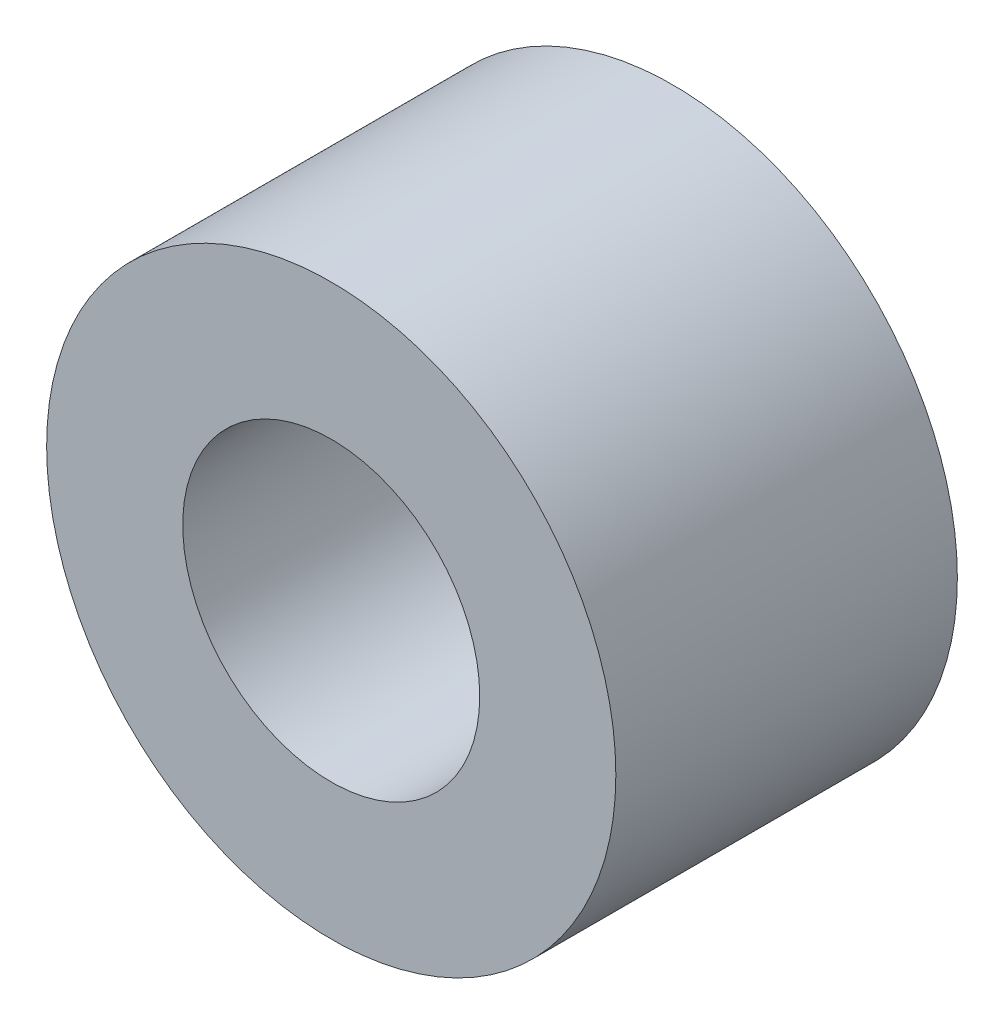
from build123d import *

# Parameters (mm, degrees)
ESQUISSE1_R        = 11.5
ESQUISSE1_R_2      = 6
BOSS_EXTRU_1_DEPTH = 13.8


with BuildPart() as part:
    # Esquisse1 → Boss.-Extru.1 (new body)
    with BuildSketch(Plane.XY):
        Circle(ESQUISSE1_R)
        Circle(ESQUISSE1_R_2, mode=Mode.SUBTRACT)
    extrude(amount=BOSS_EXTRU_1_DEPTH)


solid = part.part
